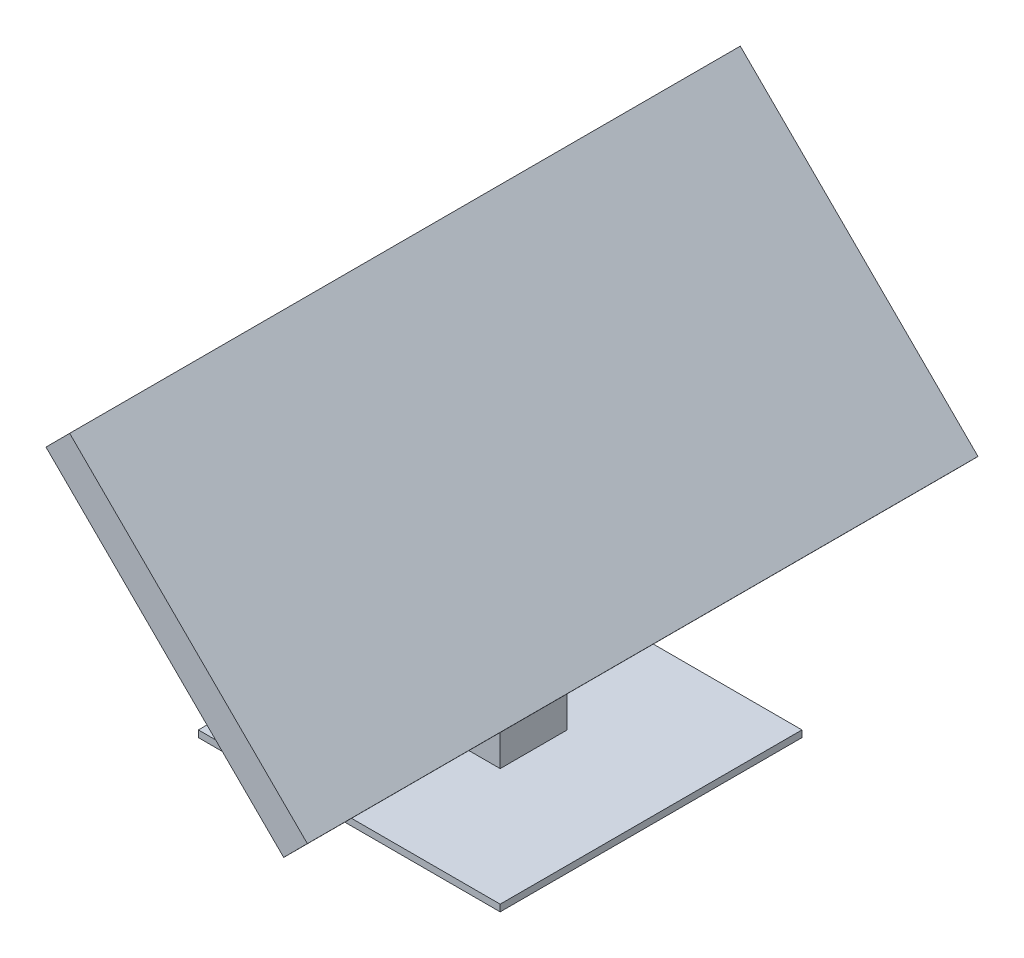
from build123d import *

# Parameters (mm, degrees)
SKETCH2_W            = 45
SKETCH2_H            = 45
BOSS_EXTRUDE1_DEPTH  = 1
SKETCH4_W            = 10
SKETCH4_H            = 10
BOSS_EXTRUDE3_DEPTH  = 40
CUT_EXTRUDE4_DEPTH   = 30
SKETCH19_W           = 50
SKETCH19_H           = 100
BOSS_EXTRUDE10_DEPTH = 5


with BuildPart() as part:
    # Sketch2 → Boss-Extrude1 (new body)
    with BuildSketch(Plane(origin=(0, 0, 0), x_dir=(1, 0, 0), z_dir=(0, 1, 0))):
        with Locations((22.5, 22.5)):
            Rectangle(SKETCH2_W, SKETCH2_H)
    extrude(amount=BOSS_EXTRUDE1_DEPTH)

    # Sketch4 → Boss-Extrude3 (add)
    with BuildSketch(Plane(origin=(0, 1, 0), x_dir=(1, 0, 0), z_dir=(0, 1, 0))):
        with Locations((22.5, 22.5)):
            Rectangle(SKETCH4_W, SKETCH4_H)
    extrude(amount=BOSS_EXTRUDE3_DEPTH)

    # Sketch10 → Cut-Extrude4 (cut)
    with BuildSketch(Plane(origin=(17.5, 41, -17.5), x_dir=(1, 0, 0), z_dir=(0, 0, 1))):
        Polygon((0, 0), (10, -9.949648776), (17.910752022, -1.998863577), (8.35816631, 7.505623697), align=None)
    extrude(amount=-CUT_EXTRUDE4_DEPTH, mode=Mode.SUBTRACT)

    # Sketch19 → Boss-Extrude10 (add)
    with BuildSketch(Plane(origin=(29.205570589, 29.353368392, 0), x_dir=(0.708889201, -0.705319857, 0), z_dir=(0.705319857, 0.708889201, 0))):
        with Locations((-9.459264691, 22.5)):
            Rectangle(SKETCH19_W, SKETCH19_H)
    extrude(amount=BOSS_EXTRUDE10_DEPTH)


solid = part.part
